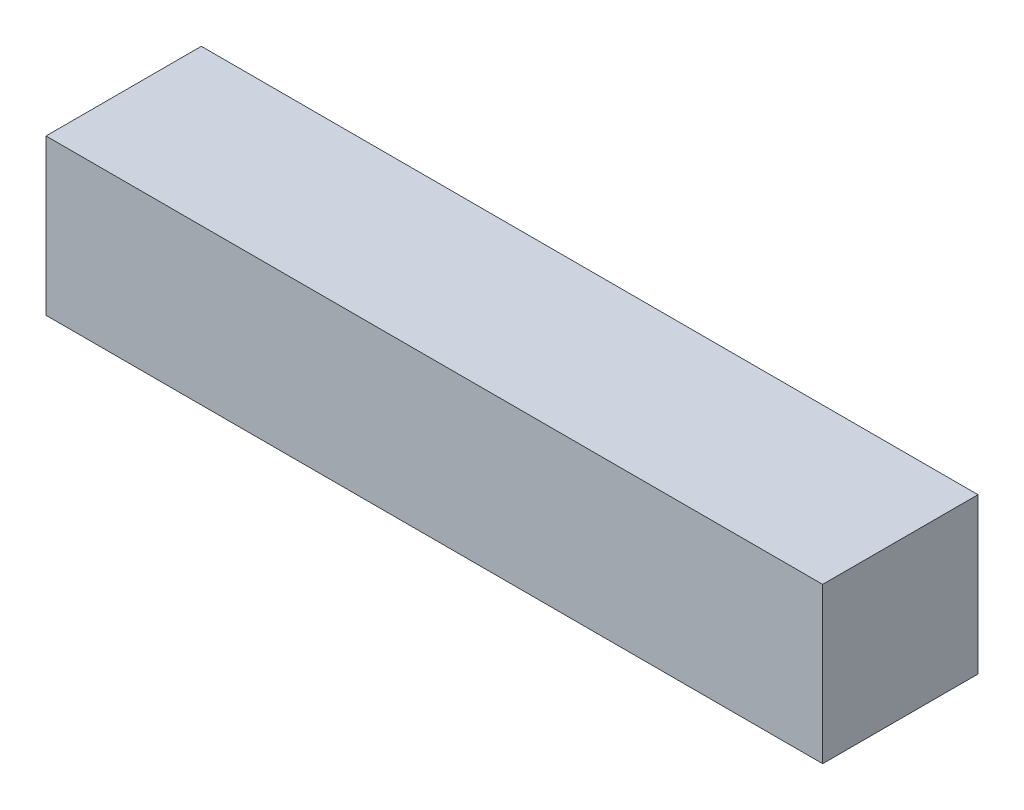
from build123d import *

# Parameters (mm, degrees)
SKETCH2_W           = 100
SKETCH2_H           = 20
BOSS_EXTRUDE1_DEPTH = 20


with BuildPart() as part:
    # Sketch2 → Boss-Extrude1 (new body)
    with BuildSketch(Plane.XY):
        with Locations((50, 10)):
            Rectangle(SKETCH2_W, SKETCH2_H)
    extrude(amount=BOSS_EXTRUDE1_DEPTH)


solid = part.part
